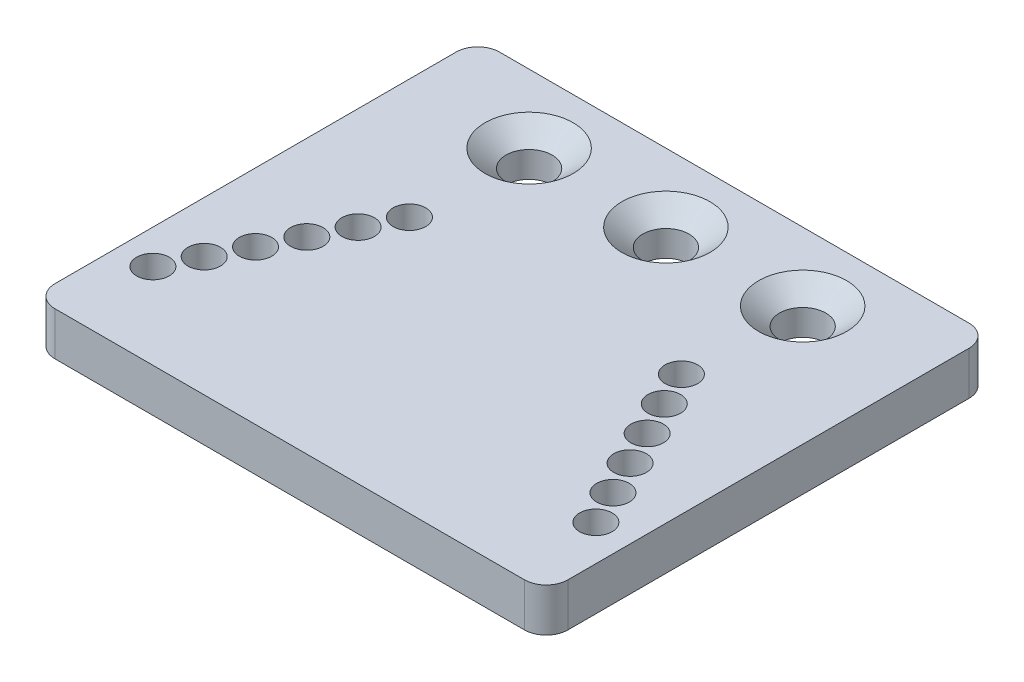
from build123d import *

# Parameters (mm, degrees)
SKETCH1_R                                           = 2.38125
SKETCH1_R_2                                         = 3.3
BOSS_EXTRUDE1_DEPTH                                 = 6.35
CSK_FOR_1_4_FLAT_HEAD_MACHINE_SCREW_100_D           = 6.7564
CSK_FOR_1_4_FLAT_HEAD_MACHINE_SCREW_100_DEPTH       = 6.35
CSK_FOR_1_4_FLAT_HEAD_MACHINE_SCREW_100_CSINK_D     = 12.8778
CSK_FOR_1_4_FLAT_HEAD_MACHINE_SCREW_100_CSINK_ANGLE = 100


with BuildPart() as part:
    # Sketch1 → Boss-Extrude1 (new body)
    with BuildSketch(Plane(origin=(0, 0, 0), x_dir=(1, 0, 0), z_dir=(0, 1, 0))):
        with BuildLine():
            Line((3.175, 0), (71.825, 0))
            ThreePointArc((71.825, 0), (74.07006403, 0.92993597), (75, 3.175))
            Line((75, 3.175), (75, 61.825))
            ThreePointArc((75, 61.825), (74.07006403, 64.07006403), (71.825, 65))
            Line((71.825, 65), (3.175, 65))
            ThreePointArc((3.175, 65), (0.92993597, 64.07006403), (0, 61.825))
            Line((0, 61.825), (0, 3.175))
            ThreePointArc((0, 3.175), (0.92993597, 0.92993597), (3.175, 0))
        make_face()
        with Locations((5, 12.5)):
            Circle(SKETCH1_R, mode=Mode.SUBTRACT)
        with Locations((69.7625, 12.5)):
            Circle(SKETCH1_R, mode=Mode.SUBTRACT)
        with Locations((7.5, 17.5)):
            Circle(SKETCH1_R, mode=Mode.SUBTRACT)
        with Locations((67.2625, 17.5)):
            Circle(SKETCH1_R, mode=Mode.SUBTRACT)
        with Locations((10, 22.5)):
            Circle(SKETCH1_R, mode=Mode.SUBTRACT)
        with Locations((64.7625, 22.5)):
            Circle(SKETCH1_R, mode=Mode.SUBTRACT)
        with Locations((12.5, 27.5)):
            Circle(SKETCH1_R, mode=Mode.SUBTRACT)
        with Locations((62.2625, 27.5)):
            Circle(SKETCH1_R, mode=Mode.SUBTRACT)
        with Locations((15, 32.5)):
            Circle(SKETCH1_R, mode=Mode.SUBTRACT)
        with Locations((59.7625, 32.5)):
            Circle(SKETCH1_R, mode=Mode.SUBTRACT)
        with Locations((17.5, 37.5)):
            Circle(SKETCH1_R, mode=Mode.SUBTRACT)
        with Locations((57.2625, 37.5)):
            Circle(SKETCH1_R, mode=Mode.SUBTRACT)
        with Locations((37.5, 55)):
            Circle(SKETCH1_R_2, mode=Mode.SUBTRACT)
        with Locations((17.5, 55)):
            Circle(SKETCH1_R_2, mode=Mode.SUBTRACT)
        with Locations((57.5, 55)):
            Circle(SKETCH1_R_2, mode=Mode.SUBTRACT)
    extrude(amount=BOSS_EXTRUDE1_DEPTH)

    # CSK for 1/4 Flat Head Machine Screw (100)1
    with Locations(Plane(origin=(17.5, 6.35, -55), x_dir=(0, 0, 1), z_dir=(0, 1, 0))):
        with Locations((0, 0), (0, 40), (0, 20)):
            CounterSinkHole(CSK_FOR_1_4_FLAT_HEAD_MACHINE_SCREW_100_D / 2, CSK_FOR_1_4_FLAT_HEAD_MACHINE_SCREW_100_CSINK_D / 2, depth=CSK_FOR_1_4_FLAT_HEAD_MACHINE_SCREW_100_DEPTH, counter_sink_angle=CSK_FOR_1_4_FLAT_HEAD_MACHINE_SCREW_100_CSINK_ANGLE)


solid = part.part
